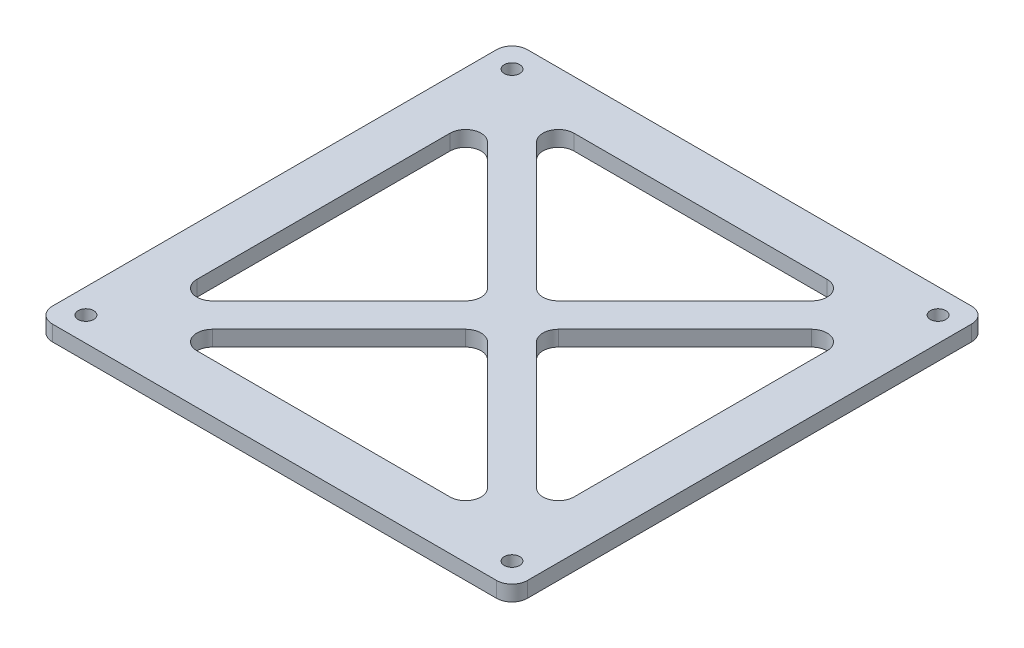
from build123d import *

# Parameters (mm, degrees)
SKETCH_1_R      = 1.5
EXTRUDE_1_DEPTH = 3


with BuildPart() as part:
    # 草圖1 → 填料-伸長1 (new body)
    with BuildSketch(Plane(origin=(0, 3, 0), x_dir=(1, 0, 0), z_dir=(0, 1, 0))):
        with BuildLine():
            Line((-46, 43), (-46, -43))
            ThreePointArc((-46, -43), (-45.121320344, -45.121320344), (-43, -46))
            Line((-43, -46), (43, -46))
            ThreePointArc((43, -46), (45.121320344, -45.121320344), (46, -43))
            Line((46, -43), (46, 43))
            ThreePointArc((46, 43), (45.121320344, 45.121320344), (43, 46))
            Line((43, 46), (-43, 46))
            ThreePointArc((-43, 46), (-45.121320344, 45.121320344), (-46, 43))
        make_face()
        with Locations((41.25, -41.25)):
            Circle(SKETCH_1_R, mode=Mode.SUBTRACT)
        with Locations((-41.25, 41.25)):
            Circle(SKETCH_1_R, mode=Mode.SUBTRACT)
        with Locations((41.25, 41.25)):
            Circle(SKETCH_1_R, mode=Mode.SUBTRACT)
        with Locations((-41.25, -41.25)):
            Circle(SKETCH_1_R, mode=Mode.SUBTRACT)
        with BuildLine():
            Line((-31.378679656, 26.628679656), (-6.871320344, 2.121320344))
            ThreePointArc((-6.871320344, 2.121320344), (-5.992640687, 0), (-6.871320344, -2.121320344))
            Line((-6.871320344, -2.121320344), (-31.378679656, -26.628679656))
            ThreePointArc((-31.378679656, -26.628679656), (-34.648050297, -27.27899791), (-36.5, -24.507359313))
            Line((-36.5, -24.507359313), (-36.5, 24.507359313))
            ThreePointArc((-36.5, 24.507359313), (-34.648050297, 27.27899791), (-31.378679656, 26.628679656))
        make_face(mode=Mode.SUBTRACT)
        with BuildLine():
            Line((24.507359313, -36.5), (-24.507359313, -36.5))
            ThreePointArc((-24.507359313, -36.5), (-27.27899791, -34.648050297), (-26.628679656, -31.378679656))
            Line((-26.628679656, -31.378679656), (-2.121320344, -6.871320344))
            ThreePointArc((-2.121320344, -6.871320344), (0, -5.992640687), (2.121320344, -6.871320344))
            Line((2.121320344, -6.871320344), (26.628679656, -31.378679656))
            ThreePointArc((26.628679656, -31.378679656), (27.27899791, -34.648050297), (24.507359313, -36.5))
        make_face(mode=Mode.SUBTRACT)
        with BuildLine():
            Line((-24.507359313, 36.5), (24.507359313, 36.5))
            ThreePointArc((24.507359313, 36.5), (27.27899791, 34.648050297), (26.628679656, 31.378679656))
            Line((26.628679656, 31.378679656), (2.121320344, 6.871320344))
            ThreePointArc((2.121320344, 6.871320344), (0, 5.992640687), (-2.121320344, 6.871320344))
            Line((-2.121320344, 6.871320344), (-26.628679656, 31.378679656))
            ThreePointArc((-26.628679656, 31.378679656), (-27.27899791, 34.648050297), (-24.507359313, 36.5))
        make_face(mode=Mode.SUBTRACT)
        with BuildLine():
            Line((36.5, 24.507359313), (36.5, -24.507359313))
            ThreePointArc((36.5, -24.507359313), (34.648050297, -27.27899791), (31.378679656, -26.628679656))
            Line((31.378679656, -26.628679656), (6.871320344, -2.121320344))
            ThreePointArc((6.871320344, -2.121320344), (5.992640687, 0), (6.871320344, 2.121320344))
            Line((6.871320344, 2.121320344), (31.378679656, 26.628679656))
            ThreePointArc((31.378679656, 26.628679656), (34.648050297, 27.27899791), (36.5, 24.507359313))
        make_face(mode=Mode.SUBTRACT)
    extrude(amount=-EXTRUDE_1_DEPTH)


solid = part.part
